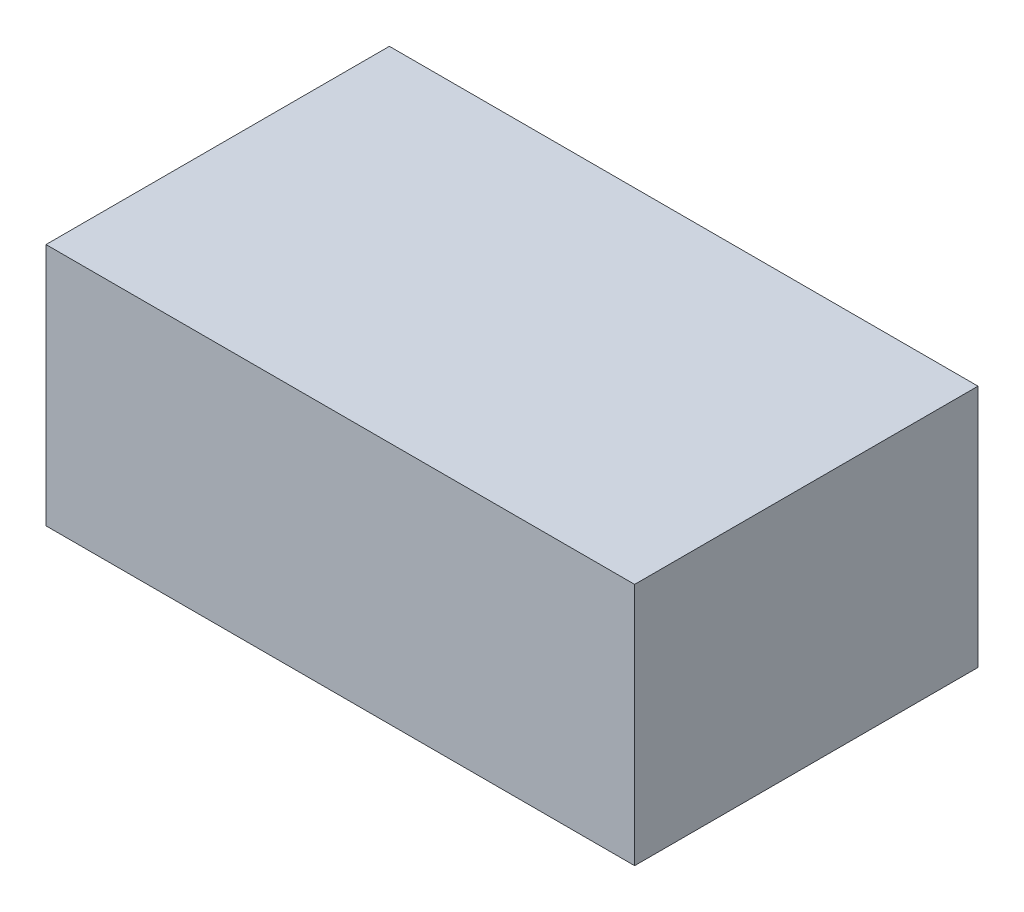
from build123d import *

# Parameters (mm, degrees)
SKETCH1_W           = 1828.8
SKETCH1_H           = 1066.8
BOSS_EXTRUDE1_DEPTH = 756.92


with BuildPart() as part:
    # Sketch1 → Boss-Extrude1 (new body)
    with BuildSketch(Plane(origin=(0, 0, 0), x_dir=(1, 0, 0), z_dir=(0, 1, 0))):
        Rectangle(SKETCH1_W, SKETCH1_H)
    extrude(amount=BOSS_EXTRUDE1_DEPTH)


solid = part.part
